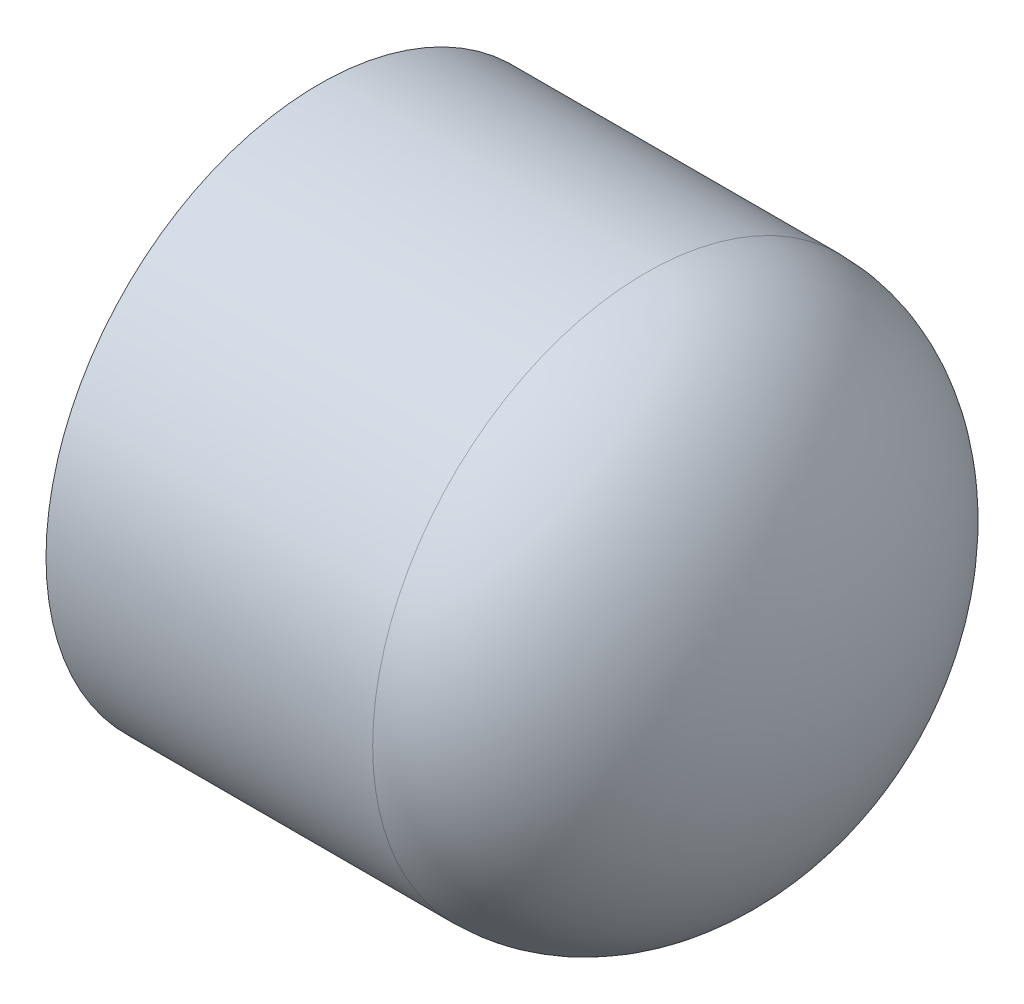
from build123d import *


with BuildPart() as part:
    # Sketch1 → Revolve1 (revolve)
    with BuildSketch(Plane.XY):
        with BuildLine():
            Line((12.3317, 0), (16.0401, 0))
            add(Edge.make_bspline(
                [(4.2799, -16.9926), (16.0401, -16.9926), (16.0401, 0)],
                knots=[3.141592654, 3.141592654, 3.141592654, 4.71238898, 4.71238898, 4.71238898], degree=2, weights=[1, 0.707106781, 1]))
            Line((4.2799, -16.9926), (-16.0401, -16.9926))
            Line((-16.0401, -16.9926), (-16.0401, -13.4366))
            Line((-16.0401, -13.4366), (4.2799, -13.2842))
            add(Edge.make_bspline(
                [(4.2799, -13.2842), (12.3317, -13.2842), (12.3317, 0)],
                knots=[0, 0, 0, 1.570796327, 1.570796327, 1.570796327], degree=2, weights=[1, 0.707106781, 1]))
        make_face()
    revolve(axis=Axis((-16.0401, 0, 0), (1, 0, 0)))


solid = part.part
